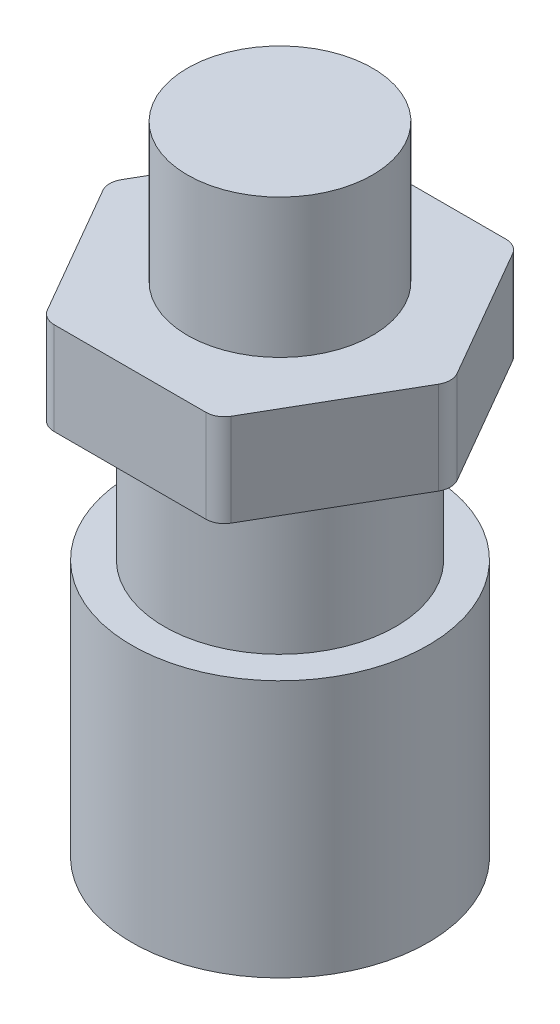
from build123d import *

# Parameters (mm, degrees)
BOSS_EXTRUDE1_DEPTH = 12.7
FILLET1_R           = 2.54
SKETCH2_R           = 20.32
BOSS_EXTRUDE4_DEPTH = 55.626
SKETCH4_R           = 20.32
SKETCH4_R_2         = 15.875
CUT_EXTRUDE1_DEPTH  = 20.32
SKETCH5_R           = 12.7
BOSS_EXTRUDE5_DEPTH = 19.05


with BuildPart() as part:
    # Sketch1 → Boss-Extrude1 (new body)
    with BuildSketch(Plane(origin=(0, 0, 0), x_dir=(1, 0, 0), z_dir=(0, 1, 0))):
        Polygon((-11.878404438, 20.574), (11.878404438, 20.574), (23.756808877, 0), (11.878404438, -20.574), (-11.878404438, -20.574), (-23.756808877, 0), align=None)
    extrude(amount=BOSS_EXTRUDE1_DEPTH)

    # Fillet1
    fillet1_edges = [part.edges().sort_by_distance(p)[0] for p in [
        (-11.878404438, 6.35, -20.574),
        (11.878404438, 6.35, -20.574),
        (23.756808877, 6.35, 0),
        (11.878404438, 6.35, 20.574),
        (-11.878404438, 6.35, 20.574),
        (-23.756808877, 6.35, 0),
    ]]
    fillet(fillet1_edges, radius=FILLET1_R)

    # Sketch2 → Boss-Extrude4 (add)
    with BuildSketch(Plane.XZ):
        Circle(SKETCH2_R)
    extrude(amount=BOSS_EXTRUDE4_DEPTH)

    # Sketch4 → Cut-Extrude1 (cut)
    with BuildSketch(Plane.XZ):
        Circle(SKETCH4_R)
        Circle(SKETCH4_R_2, mode=Mode.SUBTRACT)
    extrude(amount=CUT_EXTRUDE1_DEPTH, mode=Mode.SUBTRACT)

    # Sketch5 → Boss-Extrude5 (add)
    with BuildSketch(Plane(origin=(0, 12.7, 0), x_dir=(1, 0, 0), z_dir=(0, 1, 0))):
        Circle(SKETCH5_R)
    extrude(amount=BOSS_EXTRUDE5_DEPTH)


solid = part.part
